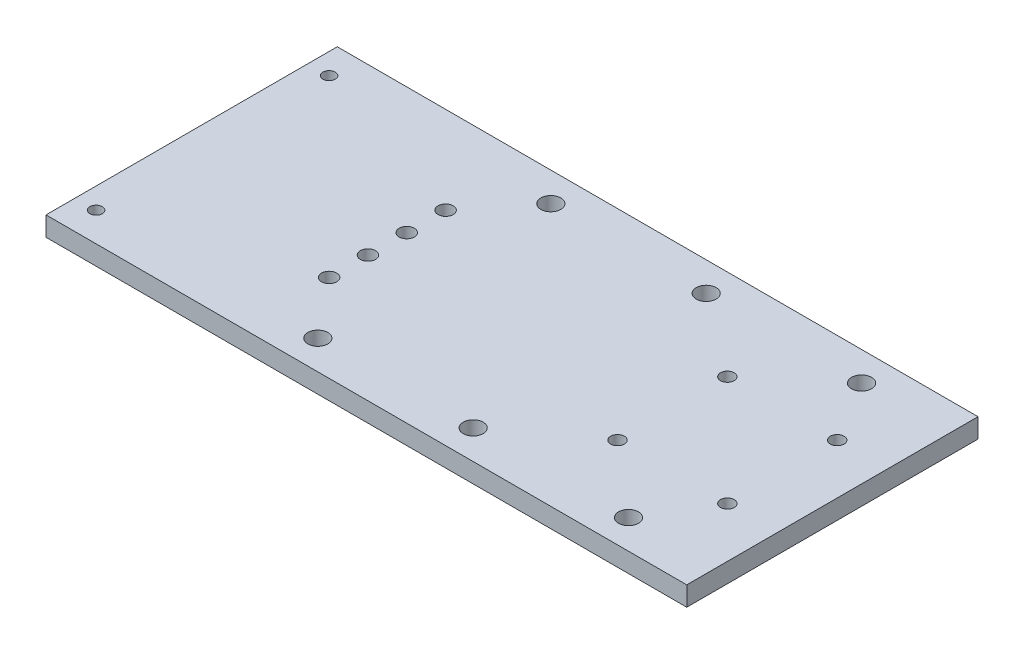
from build123d import *

# Parameters (mm, degrees)
SKETCH1_W           = 209.55
SKETCH1_H           = 95.25
BOSS_EXTRUDE1_DEPTH = 6.35
SKETCH2_R           = 2.0193
CUT_EXTRUDE1_DEPTH  = 116.266056365
SKETCH3_R           = 2.4892
CUT_EXTRUDE2_DEPTH  = 116.266056365
SKETCH4_R           = 2.2479
CUT_EXTRUDE3_DEPTH  = 116.266056365
SKETCH5_R           = 3.2639
CUT_EXTRUDE4_DEPTH  = 116.266056365


with BuildPart() as part:
    # Sketch1 → Boss-Extrude1 (new body)
    with BuildSketch(Plane(origin=(0, 0, 0), x_dir=(1, 0, 0), z_dir=(0, 1, 0))):
        Rectangle(SKETCH1_W, SKETCH1_H)
    extrude(amount=BOSS_EXTRUDE1_DEPTH)

    # Sketch2 → Cut-Extrude1 (cut, through all)
    with BuildSketch(Plane(origin=(0, 6.35, 0), x_dir=(1, 0, 0), z_dir=(0, 1, 0))):
        with Locations((-97.917, -38.1)):
            Circle(SKETCH2_R)
    cut_extrude1 = extrude(amount=-CUT_EXTRUDE1_DEPTH, mode=Mode.SUBTRACT)

    # Mirror1: Cut-Extrude1 across plane
    add(cut_extrude1.mirror(Plane.XY), mode=Mode.SUBTRACT)

    # Sketch3 → Cut-Extrude2 (cut, through all)
    with BuildSketch(Plane(origin=(0, 6.35, 0), x_dir=(1, 0, 0), z_dir=(0, 1, 0))):
        with Locations((-40.767, -6.35)):
            Circle(SKETCH3_R)
        with Locations((-40.767, -19.05)):
            Circle(SKETCH3_R)
    cut_extrude2 = extrude(amount=-CUT_EXTRUDE2_DEPTH, mode=Mode.SUBTRACT)

    # Mirror2: Cut-Extrude2 across plane
    add(cut_extrude2.mirror(Plane.XY), mode=Mode.SUBTRACT)

    # Sketch4 → Cut-Extrude3 (cut, through all)
    with BuildSketch(Plane(origin=(0, 6.35, 0), x_dir=(1, 0, 0), z_dir=(0, 1, 0))):
        with Locations((52.47132, 17.96034)):
            Circle(SKETCH4_R)
        with Locations((88.392, 17.96034)):
            Circle(SKETCH4_R)
        with Locations((88.392, -17.96034)):
            Circle(SKETCH4_R)
        with Locations((52.47132, -17.96034)):
            Circle(SKETCH4_R)
    extrude(amount=-CUT_EXTRUDE3_DEPTH, mode=Mode.SUBTRACT)

    # Sketch5 → Cut-Extrude4 (cut, through all)
    with BuildSketch(Plane(origin=(0, 6.35, 0), x_dir=(1, 0, 0), z_dir=(0, 1, 0))):
        with Locations((-25.4, 38.1)):
            Circle(SKETCH5_R)
        with Locations((25.4, 38.1)):
            Circle(SKETCH5_R)
        with Locations((76.2, 38.1)):
            Circle(SKETCH5_R)
    cut_extrude4 = extrude(amount=-CUT_EXTRUDE4_DEPTH, mode=Mode.SUBTRACT)

    # Mirror3: Cut-Extrude4 across plane
    add(cut_extrude4.mirror(Plane.XY), mode=Mode.SUBTRACT)


solid = part.part
